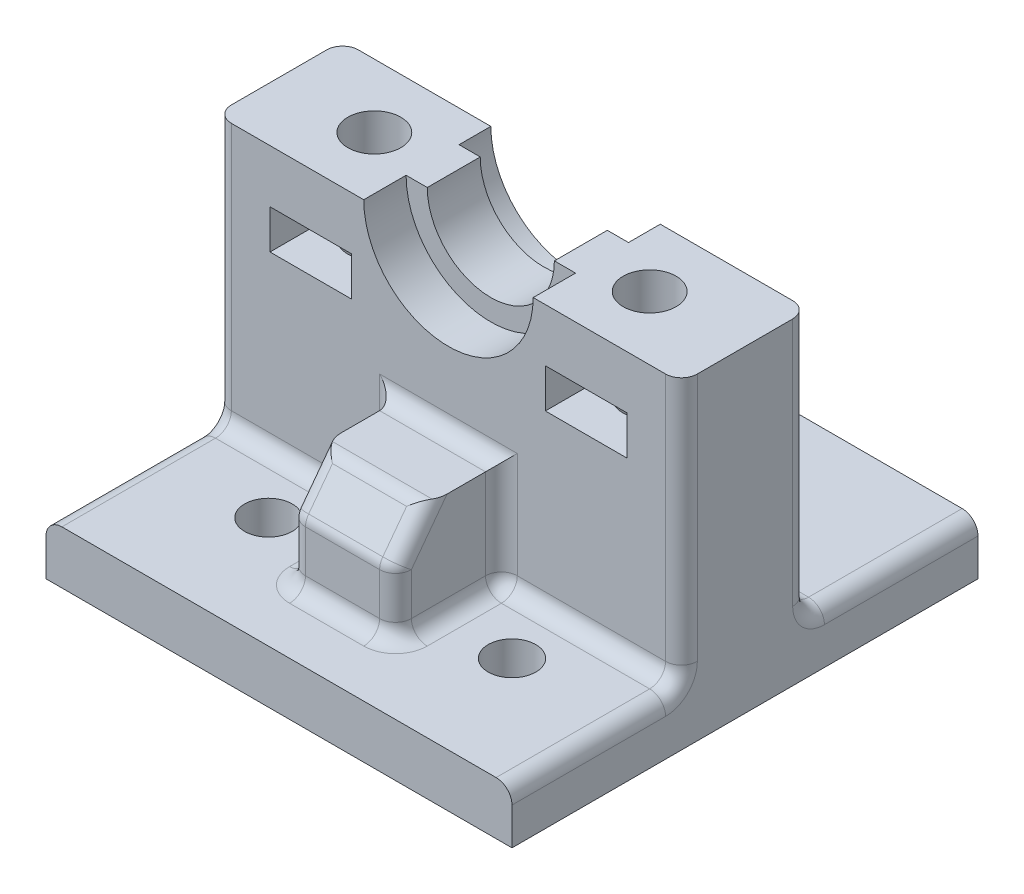
from build123d import *

# Parameters (mm, degrees)
SKETCH1_W           = 44
SKETCH1_H           = 44
BOSS_EXTRUDE1_DEPTH = 5
SKETCH2_W           = 44
SKETCH2_H           = 12
BOSS_EXTRUDE2_DEPTH = 25
SKETCH3_R           = 2.5
CUT_EXTRUDE1_DEPTH  = 15
SKETCH4_W           = 7.7
SKETCH4_H           = 3.7
CUT_EXTRUDE2_DEPTH  = 29
SKETCH6_R           = 8
CUT_EXTRUDE3_DEPTH  = 4
CUT_EXTRUDE4_DEPTH  = 3
BOSS_EXTRUDE3_DEPTH = 5
SKETCH10_R          = 2.25
CUT_EXTRUDE5_DEPTH  = 10
FILLET2_R           = 1.5


with BuildPart() as part:
    # Sketch1 → Boss-Extrude1 (new body)
    with BuildSketch(Plane(origin=(0, 0, 0), x_dir=(1, 0, 0), z_dir=(0, 1, 0))):
        with Locations((22, 22)):
            Rectangle(SKETCH1_W, SKETCH1_H)
    extrude(amount=BOSS_EXTRUDE1_DEPTH)

    # Sketch2 → Boss-Extrude2 (add)
    with BuildSketch(Plane(origin=(0, 5, 0), x_dir=(1, 0, 0), z_dir=(0, 1, 0))):
        with Locations((22, 22)):
            Rectangle(SKETCH2_W, SKETCH2_H)
    extrude(amount=BOSS_EXTRUDE2_DEPTH)

    # Sketch3 → Cut-Extrude1 (cut)
    with BuildSketch(Plane(origin=(0, 30, 0), x_dir=(1, 0, 0), z_dir=(0, 1, 0))):
        with Locations((35, 22)):
            Circle(SKETCH3_R)
        with Locations((9, 22)):
            Circle(SKETCH3_R)
    extrude(amount=-CUT_EXTRUDE1_DEPTH, mode=Mode.SUBTRACT)

    # Sketch4 → Cut-Extrude2 (cut, through all)
    with BuildSketch(Plane.XY.offset(-16)):
        with Locations((9, 23.15)):
            Rectangle(SKETCH4_W, SKETCH4_H)
        with BuildLine():
            Line((16, 30), (28, 30))
            ThreePointArc((28, 30), (22, 36), (16, 30))
        make_face()
        with BuildLine():
            ThreePointArc((16, 30), (22, 24), (28, 30))
            Line((28, 30), (16, 30))
        make_face()
        with Locations((35, 23.15)):
            Rectangle(SKETCH4_W, SKETCH4_H)
    extrude(amount=-CUT_EXTRUDE2_DEPTH, mode=Mode.SUBTRACT)

    # Sketch6 → Cut-Extrude3 (cut)
    with BuildSketch(Plane.XY.offset(-16)):
        with Locations((22, 30)):
            Circle(SKETCH6_R)
    extrude(amount=-CUT_EXTRUDE3_DEPTH, mode=Mode.SUBTRACT)

    # Sketch7 → Cut-Extrude4 (cut)
    with BuildSketch(Plane(origin=(0, 0, -28), x_dir=(-1, 0, 0), z_dir=(0, 0, -1))):
        with BuildLine():
            Line((-30, 30), (-14, 30))
            ThreePointArc((-14, 30), (-22, 22), (-30, 30))
        make_face()
    extrude(amount=-CUT_EXTRUDE4_DEPTH, mode=Mode.SUBTRACT)

    # Sketch8 → Boss-Extrude3 (add, symmetric)
    with BuildSketch(Plane(origin=(22, 0, 0), x_dir=(0, 0, -1), z_dir=(1, 0, 0))):
        Polygon((16, 5), (6, 5), (6, 11), (9, 15), (16, 15), align=None)
    extrude(amount=BOSS_EXTRUDE3_DEPTH, both=True)

    # Sketch10 → Cut-Extrude5 (cut)
    with BuildSketch(Plane(origin=(0, 5, 0), x_dir=(1, 0, 0), z_dir=(0, 1, 0))):
        with Locations((33.5, 10.5)):
            Circle(SKETCH10_R)
        with Locations((10.5, 10.5)):
            Circle(SKETCH10_R)
        with Locations((33.5, 33.5)):
            Circle(SKETCH10_R)
        with Locations((10.5, 33.5)):
            Circle(SKETCH10_R)
    extrude(amount=-CUT_EXTRUDE5_DEPTH, mode=Mode.SUBTRACT)

    # Fillet2
    fillet2_edges = [part.edges().sort_by_distance(p)[0] for p in [
        (44, 5, -8),
        (35.5, 5, -16),
        (17, 10, -16),
        (22, 15, -16),
        (17, 13, -7.5),
        (22, 15, -9),
        (17, 8, -6),
        (22, 11, -6),
        (17, 5, -11),
        (22, 5, -6),
        (27, 10, -16),
        (27, 13, -7.5),
        (27, 8, -6),
        (27, 5, -11),
        (0, 5, -8),
        (44, 5, -36),
        (0, 17.5, -28),
        (8.5, 5, -16),
        (0, 17.5, -16),
        (44, 17.5, -16),
        (22, 5, -28),
        (44, 17.5, -28),
        (0, 5, -36),
    ]]
    fillet(fillet2_edges, radius=FILLET2_R)


solid = part.part
